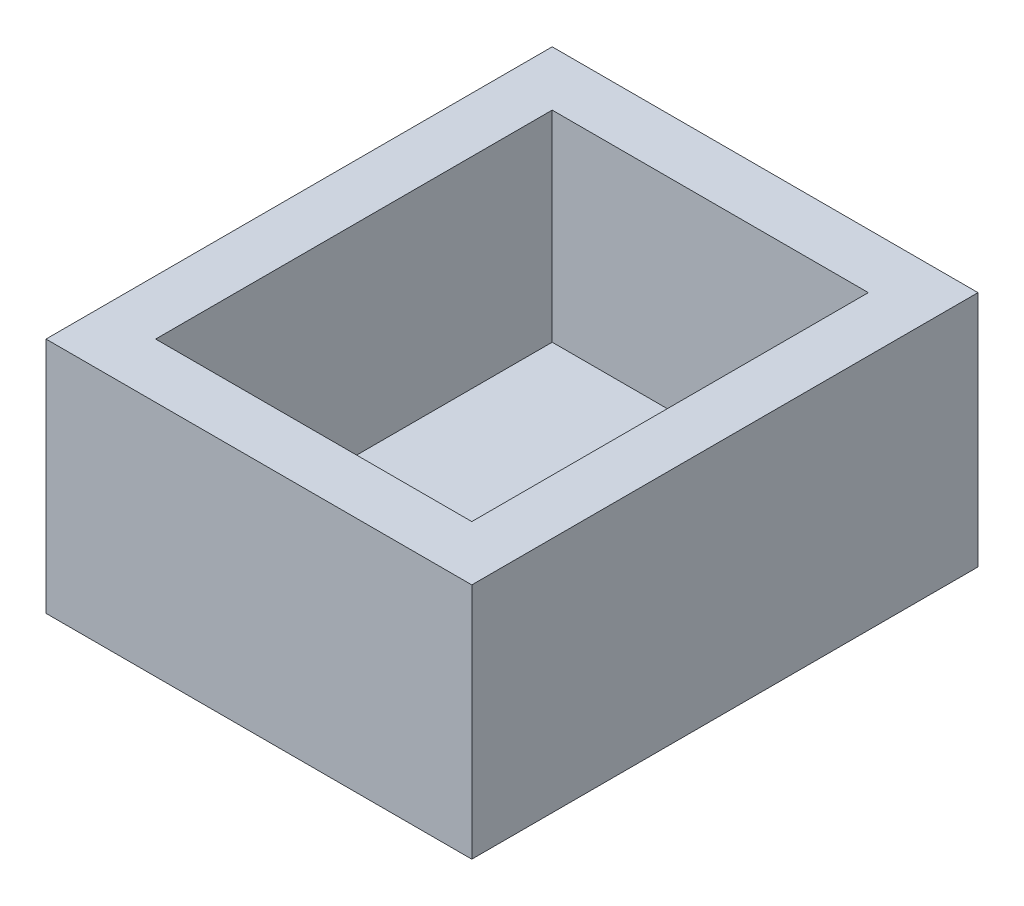
from build123d import *

# Parameters (mm, degrees)
SKETCH1_W           = 23.3
SKETCH1_H           = 27.7
SKETCH1_W_2         = 17.3
SKETCH1_H_2         = 21.7
BOSS_EXTRUDE1_DEPTH = 13
SKETCH2_W           = 17.3
SKETCH2_H           = 21.7
SKETCH2_R           = 1.75
BOSS_EXTRUDE2_DEPTH = 2


with BuildPart() as part:
    # Sketch1 → Boss-Extrude1 (new body)
    with BuildSketch(Plane(origin=(0, 0, 0), x_dir=(1, 0, 0), z_dir=(0, 1, 0))):
        with Locations((0, 8.983417287)):
            Rectangle(SKETCH1_W, SKETCH1_H)
        with Locations((0, 8.983417287)):
            Rectangle(SKETCH1_W_2, SKETCH1_H_2, mode=Mode.SUBTRACT)
    extrude(amount=BOSS_EXTRUDE1_DEPTH)

    # Sketch2 → Boss-Extrude2 (add)
    with BuildSketch(Plane.XZ):
        with Locations((0, -8.983417287)):
            Rectangle(SKETCH2_W, SKETCH2_H)
        with Locations((6.24, -0.707949912)):
            Circle(SKETCH2_R, mode=Mode.SUBTRACT)
    extrude(amount=-BOSS_EXTRUDE2_DEPTH)


solid = part.part
